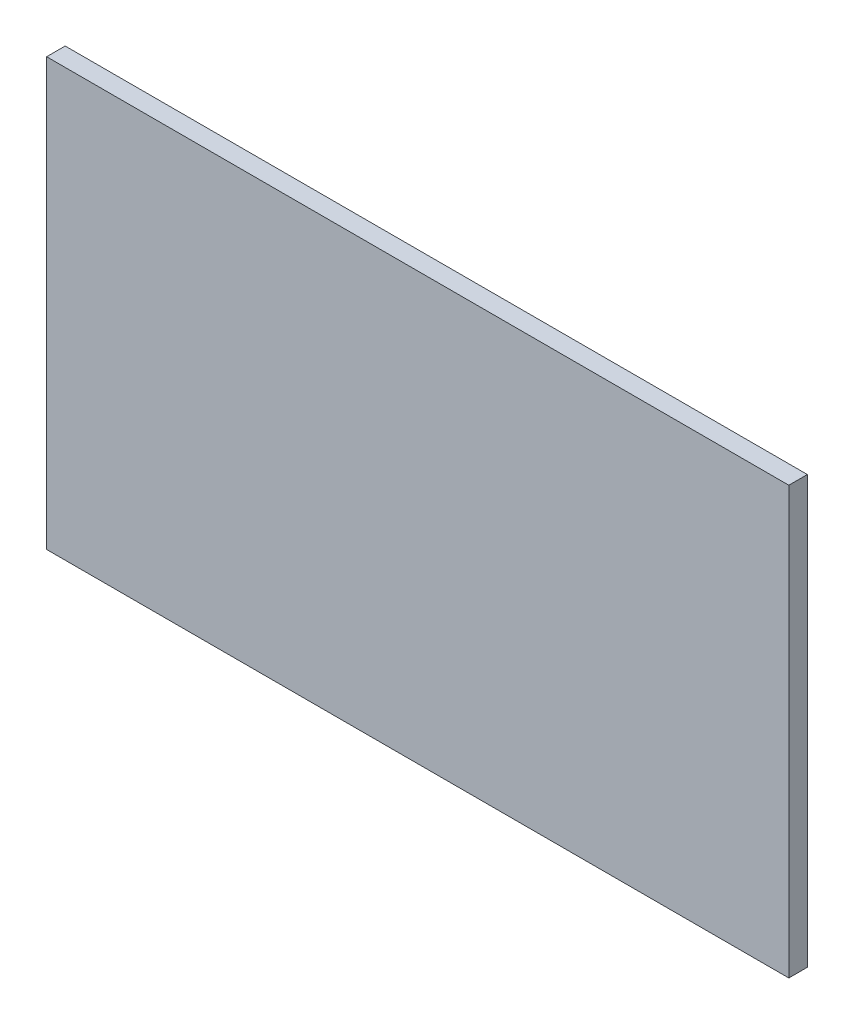
from build123d import *

# Parameters (mm, degrees)
FACADEANTERIEURE_W = 800
FACADEANTERIEURE_H = 460
BOSS_EXTRU_1_DEPTH = 20


with BuildPart() as part:
    # facadeanterieure → Boss.-Extru.1 (new body)
    with BuildSketch(Plane.XY):
        Rectangle(FACADEANTERIEURE_W, FACADEANTERIEURE_H)
    extrude(amount=BOSS_EXTRU_1_DEPTH)


solid = part.part
